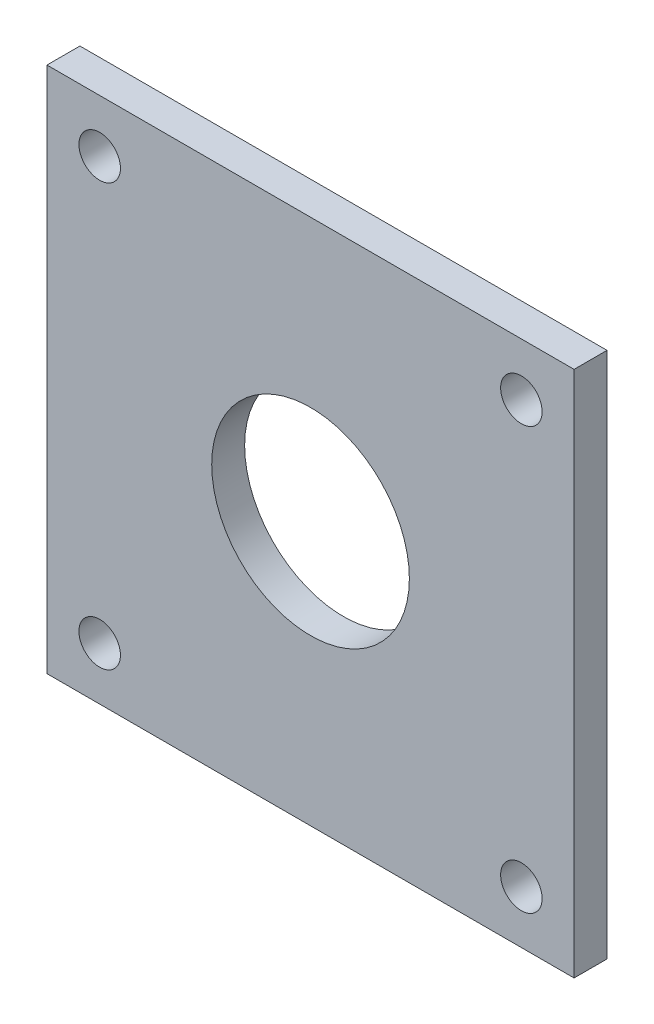
from build123d import *

# Parameters (mm, degrees)
SKETCH2_W           = 50.8
SKETCH2_H           = 50.8
SKETCH2_R           = 2
SKETCH2_R_2         = 9.525
BOSS_EXTRUDE1_DEPTH = 3.175


with BuildPart() as part:
    # Sketch2 → Boss-Extrude1 (new body)
    with BuildSketch(Plane.XY):
        with Locations((25.4, 25.4)):
            Rectangle(SKETCH2_W, SKETCH2_H)
        with Locations((5.08, 45.72)):
            Circle(SKETCH2_R, mode=Mode.SUBTRACT)
        with Locations((45.72, 45.72)):
            Circle(SKETCH2_R, mode=Mode.SUBTRACT)
        with Locations((45.72, 5.08)):
            Circle(SKETCH2_R, mode=Mode.SUBTRACT)
        with Locations((5.08, 5.08)):
            Circle(SKETCH2_R, mode=Mode.SUBTRACT)
        with Locations((25.4, 25.4)):
            Circle(SKETCH2_R_2, mode=Mode.SUBTRACT)
    extrude(amount=BOSS_EXTRUDE1_DEPTH)


solid = part.part
